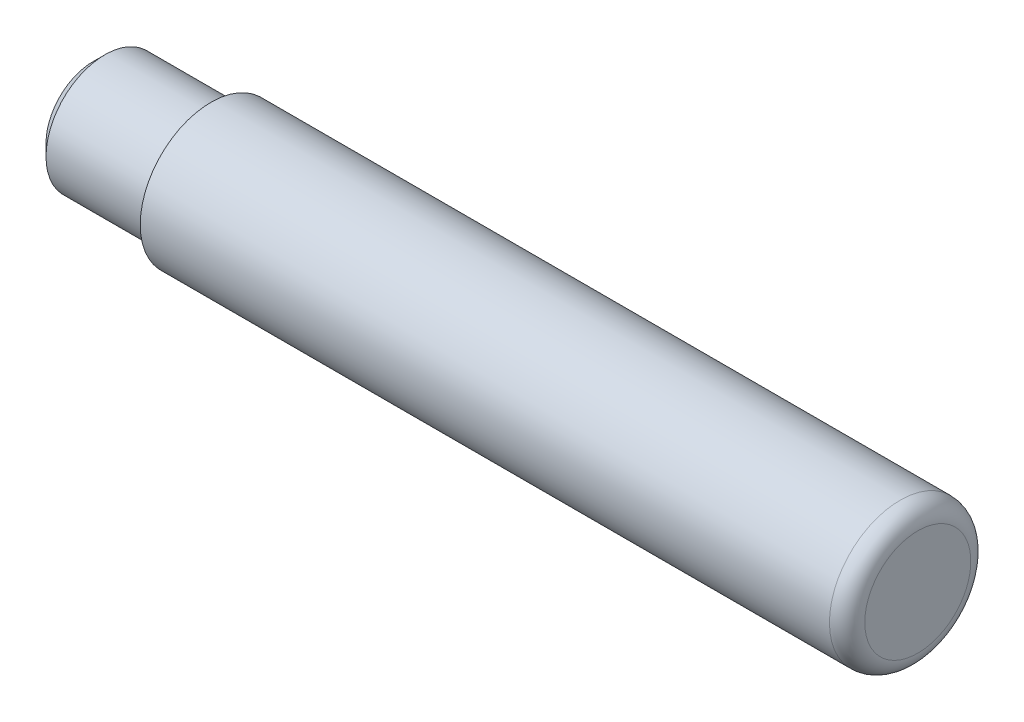
from build123d import *


with BuildPart() as part:
    # Esquisse1 → Révolution1 (revolve)
    with BuildSketch(Plane.XY):
        with BuildLine():
            Line((0, 0), (0, 4.5))
            ThreePointArc((0, 4.5), (-0.439339828, 5.560660172), (-1.5, 6))
            Line((-1.5, 6), (-60, 6))
            Line((-60, 6), (-60, 5))
            Line((-60, 5), (-69, 5))
            Line((-69, 5), (-70, 4))
            Line((-70, 4), (-70, 0))
            Line((-70, 0), (0, 0))
        make_face()
    revolve(axis=Axis((-70, 0, 0), (1, 0, 0)))


solid = part.part
